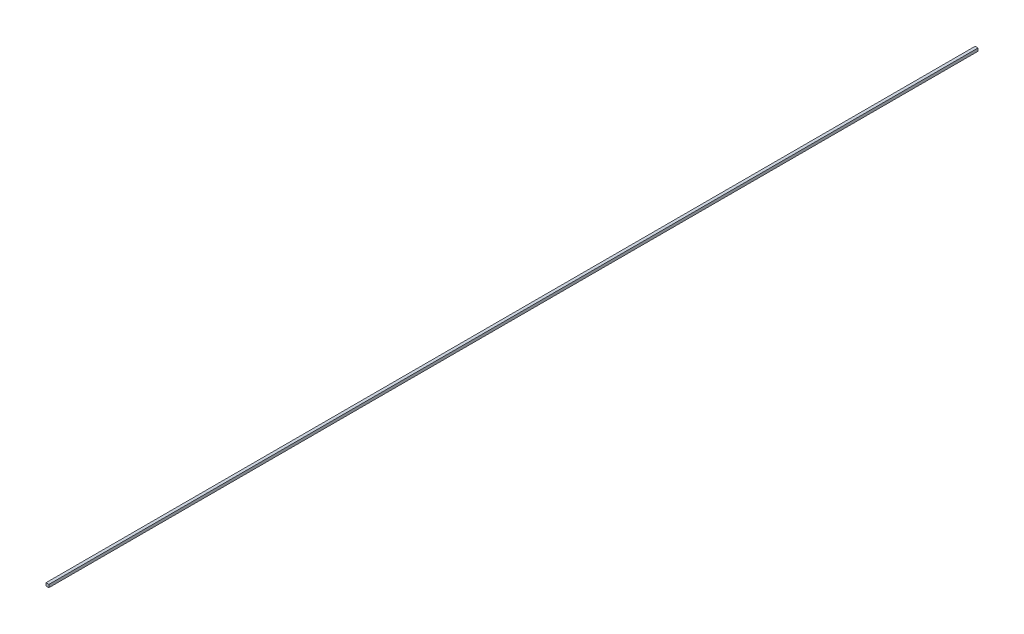
from build123d import *

# Parameters (mm, degrees)
SKETCH_1_W      = 2
SKETCH_1_H      = 2
EXTRUDE_1_DEPTH = 640.8


with BuildPart() as part:
    # ｽｹｯﾁ1 → ﾎﾞｽ - 押し出し1 (new body)
    with BuildSketch(Plane.XY):
        Rectangle(SKETCH_1_W, SKETCH_1_H)
    extrude(amount=EXTRUDE_1_DEPTH)


solid = part.part
